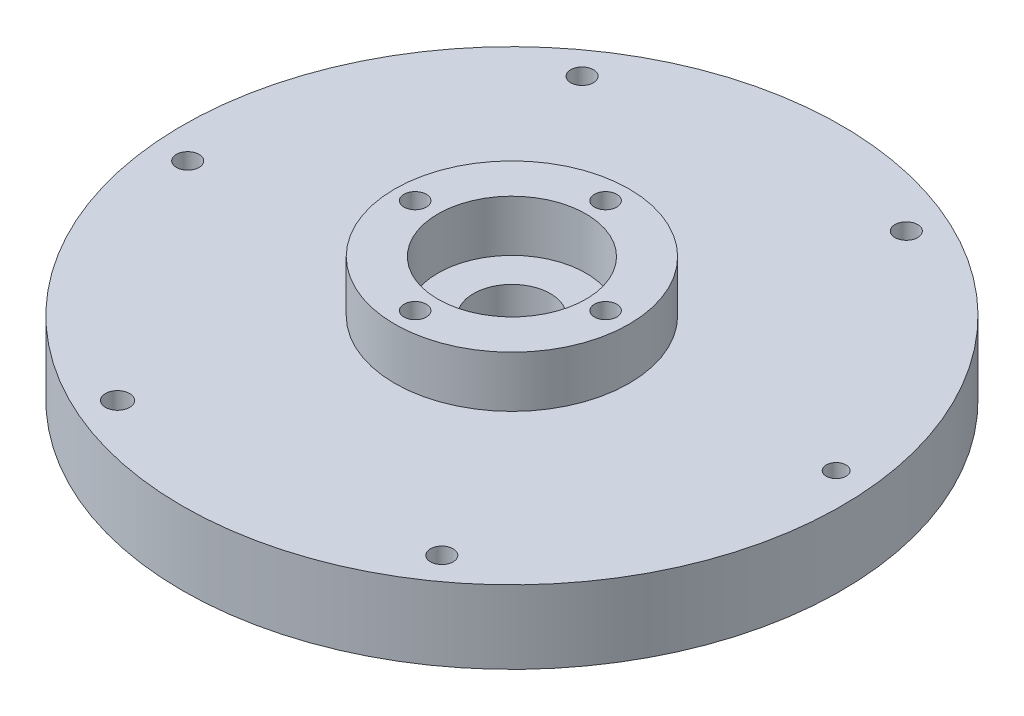
from build123d import *

# Parameters (mm, degrees)
SKETCH1_R           = 45
SKETCH1_R_2         = 9.55
SKETCH1_R_3         = 1.55
BOSS_EXTRUDE1_DEPTH = 5
SKETCH3_R           = 45
SKETCH3_R_2         = 5.25
SKETCH3_R_3         = 1.55
SKETCH3_R_4         = 1.347664629
SKETCH3_R_5         = 1.649528324
BOSS_EXTRUDE2_DEPTH = 5
SKETCH4_R           = 16
SKETCH4_R_2         = 10.1
BOSS_EXTRUDE3_DEPTH = 7
SKETCH5_R           = 1.525
CUT_EXTRUDE1_DEPTH  = 46
SKETCH8_R           = 3.275737446
CUT_EXTRUDE4_DEPTH  = 7


with BuildPart() as part:
    # Sketch1 → Boss-Extrude1 (new body)
    with BuildSketch(Plane(origin=(0, 0, 0), x_dir=(1, 0, 0), z_dir=(0, 1, 0))):
        Circle(SKETCH1_R)
        Circle(SKETCH1_R_2, mode=Mode.SUBTRACT)
        with Locations((23.534905201, -33.114037619)):
            Circle(SKETCH1_R_3, mode=Mode.SUBTRACT)
        with Locations((-16.9101452, -36.938844589)):
            Circle(SKETCH1_R_3, mode=Mode.SUBTRACT)
        with Locations((-40.4450504, -3.82480697)):
            Circle(SKETCH1_R_3, mode=Mode.SUBTRACT)
        with Locations((-23.534905201, 33.114037619)):
            Circle(SKETCH1_R_3, mode=Mode.SUBTRACT)
        with Locations((16.9101452, 36.938844589)):
            Circle(SKETCH1_R_3, mode=Mode.SUBTRACT)
        with Locations((40.4450504, 3.82480697)):
            Circle(SKETCH1_R_3, mode=Mode.SUBTRACT)
    extrude(amount=BOSS_EXTRUDE1_DEPTH)

    # Sketch3 → Boss-Extrude2 (add)
    with BuildSketch(Plane(origin=(0, 5, 0), x_dir=(1, 0, 0), z_dir=(0, 1, 0))):
        Circle(SKETCH3_R)
        Circle(SKETCH3_R_2, mode=Mode.SUBTRACT)
        with Locations((16.9101452, 36.938844589)):
            Circle(SKETCH3_R_3, mode=Mode.SUBTRACT)
        with Locations((40.4450504, 3.82480697)):
            Circle(SKETCH3_R_4, mode=Mode.SUBTRACT)
        with Locations((23.534905201, -33.114037619)):
            Circle(SKETCH3_R_3, mode=Mode.SUBTRACT)
        with Locations((-16.9101452, -36.938844589)):
            Circle(SKETCH3_R_5, mode=Mode.SUBTRACT)
        with Locations((-40.4450504, -3.82480697)):
            Circle(SKETCH3_R_3, mode=Mode.SUBTRACT)
        with Locations((-23.534905201, 33.114037619)):
            Circle(SKETCH3_R_3, mode=Mode.SUBTRACT)
    extrude(amount=BOSS_EXTRUDE2_DEPTH)

    # Sketch4 → Boss-Extrude3 (add)
    with BuildSketch(Plane(origin=(0, 10, 0), x_dir=(1, 0, 0), z_dir=(0, 1, 0))):
        Circle(SKETCH4_R)
        Circle(SKETCH4_R_2, mode=Mode.SUBTRACT)
    extrude(amount=BOSS_EXTRUDE3_DEPTH)

    # Sketch5 → Cut-Extrude1 (cut)
    with BuildSketch(Plane(origin=(0, 17, 0), x_dir=(1, 0, 0), z_dir=(0, 1, 0))):
        with Locations((12.786648762, 0)):
            Circle(SKETCH5_R)
        with Locations((-0.213351238, -13)):
            Circle(SKETCH5_R)
        with Locations((-13.213351238, 0)):
            Circle(SKETCH5_R)
        with Locations((-0.213351238, 13)):
            Circle(SKETCH5_R)
    extrude(amount=-CUT_EXTRUDE1_DEPTH, mode=Mode.SUBTRACT)

    # Sketch8 → Cut-Extrude4 (cut)
    with BuildSketch(Plane.XZ):
        with Locations((-0.213351238, -13)):
            Circle(SKETCH8_R)
        with Locations((-13, 0.213351238)):
            Circle(SKETCH8_R)
        with Locations((0.213351238, 13)):
            Circle(SKETCH8_R)
        with Locations((13, -0.213351238)):
            Circle(SKETCH8_R)
    extrude(amount=-CUT_EXTRUDE4_DEPTH, mode=Mode.SUBTRACT)


solid = part.part
